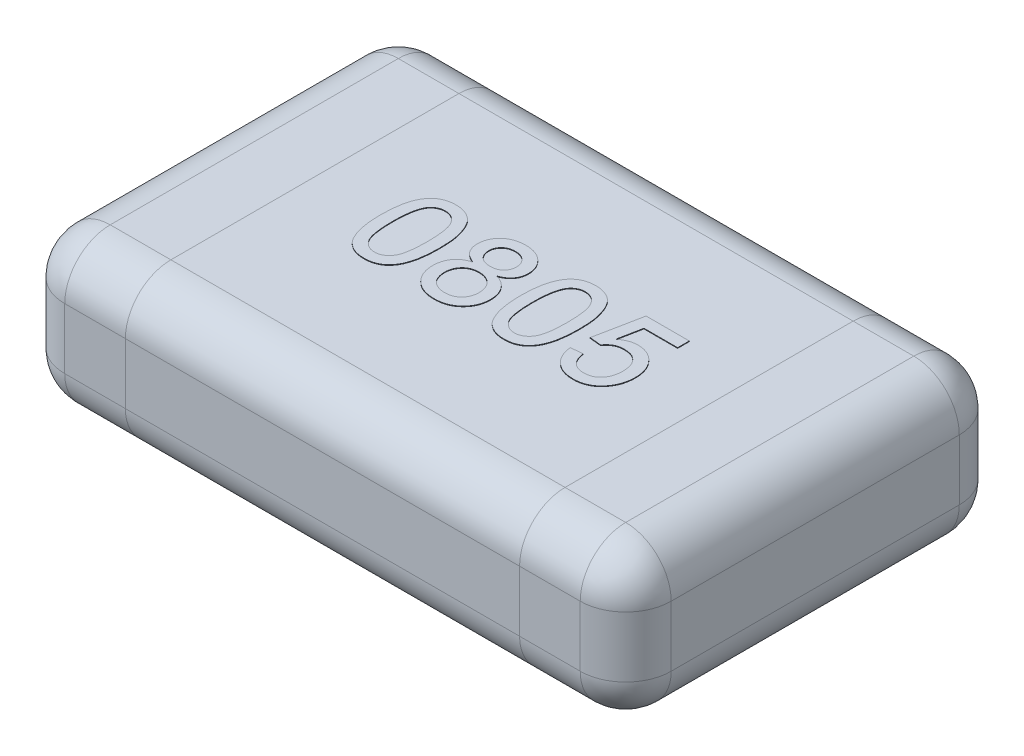
from build123d import *

# Parameters (mm, degrees)
SKETCH1_W      = 2
SKETCH1_H      = 1.25
EXTRUDE1_DEPTH = 0.5
FILLET1_R      = 0.15
EXTRUDE2_DEPTH = 0.002


with BuildPart() as part:
    # Sketch1 → Extrude1 (new body)
    with BuildSketch(Plane(origin=(0, 0, 0), x_dir=(1, 0, 0), z_dir=(0, 1, 0))):
        Rectangle(SKETCH1_W, SKETCH1_H)
    extrude(amount=EXTRUDE1_DEPTH)

    # Fillet1
    fillet1_edges = [part.edges().sort_by_distance(p)[0] for p in [
        (1, 0.5, 0),
        (0, 0.5, -0.625),
        (-1, 0.5, 0),
        (0, 0, -0.625),
        (1, 0, 0),
        (0, 0, 0.625),
        (-1, 0, 0),
        (0, 0.5, 0.625),
        (-1, 0.25, -0.625),
        (1, 0.25, -0.625),
        (1, 0.25, 0.625),
        (-1, 0.25, 0.625),
    ]]
    fillet(fillet1_edges, radius=FILLET1_R)

    # Sketch3 → Extrude2 (add)
    with BuildSketch(Plane(origin=(0, 0.5, 0), x_dir=(1, 0, 0), z_dir=(0, 1, 0))):
        with BuildLine():
            add(Edge.make_bspline(
                [(-0.430769231, -0.002043269), (-0.430730481, 0.002244006), (-0.430654586, 0.010640973), (-0.430183834, 0.022927244), (-0.42936194, 0.034595007), (-0.428135078, 0.045634129), (-0.426682243, 0.056069528), (-0.424793549, 0.06588631), (-0.422668494, 0.075106502), (-0.420118809, 0.083720493), (-0.41731754, 0.091802347), (-0.414139411, 0.0993391), (-0.410563584, 0.106322761), (-0.40676579, 0.112825754), (-0.402546105, 0.118746931), (-0.39815922, 0.124252464), (-0.393286323, 0.129140445), (-0.388130039, 0.13353664), (-0.382614442, 0.137416027), (-0.376768712, 0.140763469), (-0.370615345, 0.143719019), (-0.364037062, 0.145943957), (-0.357170429, 0.147757753), (-0.349962588, 0.149092003), (-0.342405598, 0.149878588), (-0.337241458, 0.149959072), (-0.334615385, 0.15)],
                knots=[0, 0, 0, 0, 1.2862e-05, 2.5191e-05, 3.688e-05, 4.7943e-05, 5.8507e-05, 6.8478e-05, 7.7924e-05, 8.6881e-05, 9.5415e-05, 0.000103574, 0.000111395, 0.00011894, 0.000126142, 0.000133191, 0.000140033, 0.000146812, 0.000153498, 0.000160229, 0.000167003, 0.000173941, 0.000181025, 0.000188297, 0.00019591, 0.000203786, 0.000203786, 0.000203786, 0.000203786], degree=3))
            add(Edge.make_bspline(
                [(-0.334615385, 0.15), (-0.330762593, 0.149886731), (-0.32319363, 0.149664209), (-0.312142905, 0.147849358), (-0.301728309, 0.144744777), (-0.291956608, 0.140556563), (-0.282994848, 0.135236725), (-0.274991618, 0.128769652), (-0.268033247, 0.121223246), (-0.262195674, 0.112508085), (-0.257093053, 0.102864591), (-0.252559996, 0.092249481), (-0.248462244, 0.080674651), (-0.24555439, 0.070313561), (-0.243480221, 0.061369501), (-0.242107285, 0.053992694), (-0.240967473, 0.046033077), (-0.240094223, 0.037509907), (-0.239377743, 0.028432744), (-0.238824437, 0.018795935), (-0.238543578, 0.008575397), (-0.238489398, 0.001562641), (-0.238461538, -0.002043269)],
                knots=[0, 0, 0, 0, 1.1554e-05, 2.2698e-05, 3.348e-05, 4.4085e-05, 5.4516e-05, 6.4643e-05, 7.485e-05, 8.5185e-05, 9.602e-05, 0.000107541, 0.000119781, 0.000132832, 0.000139801, 0.000147321, 0.000155335, 0.000163916, 0.000173019, 0.00018265, 0.000192871, 0.000203689, 0.000203689, 0.000203689, 0.000203689], degree=3))
            add(Edge.make_bspline(
                [(-0.238461538, -0.002043269), (-0.238501014, -0.006310407), (-0.238578138, -0.0146471), (-0.239036276, -0.026834856), (-0.239907695, -0.038414591), (-0.240979992, -0.049412832), (-0.242602154, -0.059800218), (-0.24435012, -0.069620882), (-0.246511923, -0.07883023), (-0.249034239, -0.087432298), (-0.251874941, -0.095472571), (-0.254990209, -0.103011813), (-0.258440668, -0.110044871), (-0.262329015, -0.11650315), (-0.266477343, -0.122472371), (-0.270916032, -0.127974928), (-0.275739189, -0.132931621), (-0.280941938, -0.137314631), (-0.28641881, -0.141262812), (-0.292278751, -0.144643304), (-0.298496114, -0.147443983), (-0.305029358, -0.149838424), (-0.311944772, -0.15159293), (-0.319187822, -0.152935977), (-0.326785196, -0.153726861), (-0.331969311, -0.153805841), (-0.334615385, -0.153846154)],
                knots=[0, 0, 0, 0, 1.2802e-05, 2.5011e-05, 3.658e-05, 4.7637e-05, 5.815e-05, 6.811e-05, 7.7556e-05, 8.6513e-05, 9.499e-05, 0.000103126, 0.000110974, 0.000118467, 0.000125719, 0.000132767, 0.000139652, 0.000146431, 0.000153152, 0.000159883, 0.000166686, 0.000173587, 0.000180729, 0.000188061, 0.000195673, 0.00020361, 0.00020361, 0.00020361, 0.00020361], degree=3))
            add(Edge.make_bspline(
                [(-0.334615385, -0.153846154), (-0.338084694, -0.153747192), (-0.344848894, -0.153554242), (-0.354727508, -0.152243272), (-0.363999114, -0.149935902), (-0.372741914, -0.146841394), (-0.380857634, -0.142702311), (-0.388385026, -0.137666308), (-0.395475345, -0.131850554), (-0.399556964, -0.127262057), (-0.401622596, -0.124939904)],
                knots=[0, 0, 0, 0, 1.0408e-05, 2.0292e-05, 2.9825e-05, 3.9025e-05, 4.8056e-05, 5.7073e-05, 6.616e-05, 7.5471e-05, 7.5471e-05, 7.5471e-05, 7.5471e-05], degree=3))
            add(Edge.make_bspline(
                [(-0.401622596, -0.124939904), (-0.404000186, -0.121510195), (-0.408902879, -0.11443799), (-0.414641055, -0.102379223), (-0.41975961, -0.089104214), (-0.423776737, -0.074352508), (-0.426923149, -0.058241513), (-0.429195644, -0.040739616), (-0.430481652, -0.021854376), (-0.430671207, -0.008796046), (-0.430769231, -0.002043269)],
                knots=[0, 0, 0, 0, 1.2501e-05, 2.5778e-05, 3.993e-05, 5.5152e-05, 7.157e-05, 8.9147e-05, 0.000108063, 0.000128321, 0.000128321, 0.000128321, 0.000128321], degree=3))
        make_face()
        with BuildLine():
            add(Edge.make_bspline(
                [(-0.392307692, -0.001923077), (-0.392269503, -0.007693168), (-0.3921964, -0.018738399), (-0.391432655, -0.034518417), (-0.390117899, -0.048754147), (-0.388379705, -0.061425879), (-0.386084585, -0.072550754), (-0.383202791, -0.082100422), (-0.379954324, -0.090189501), (-0.375934407, -0.096717734), (-0.371533042, -0.102039196), (-0.366988934, -0.106615825), (-0.362195175, -0.110505855), (-0.357183043, -0.113749347), (-0.351874773, -0.116205105), (-0.346328409, -0.117985045), (-0.340542745, -0.119009373), (-0.336602445, -0.119156549), (-0.334615385, -0.119230769)],
                knots=[0, 0, 0, 0, 1.7309e-05, 3.3134e-05, 4.7378e-05, 6.0186e-05, 7.1489e-05, 8.1413e-05, 9.0085e-05, 9.7558e-05, 0.000104306, 0.000110765, 0.000116876, 0.000122794, 0.000128628, 0.000134368, 0.000140227, 0.000146187, 0.000146187, 0.000146187, 0.000146187], degree=3))
            add(Edge.make_bspline(
                [(-0.334615385, -0.119230769), (-0.332628822, -0.119154928), (-0.328689509, -0.119004535), (-0.322890476, -0.118002795), (-0.317365692, -0.116131225), (-0.312065336, -0.11368414), (-0.307016775, -0.110514577), (-0.30224656, -0.106609854), (-0.297678514, -0.102035942), (-0.29329692, -0.096652628), (-0.289307629, -0.090094213), (-0.285998225, -0.082011723), (-0.283161342, -0.072445331), (-0.280853628, -0.061326124), (-0.279108264, -0.048674427), (-0.277801457, -0.03447818), (-0.2770326, -0.018718466), (-0.276960704, -0.007693194), (-0.276923077, -0.001923077)],
                knots=[0, 0, 0, 0, 5.96e-06, 1.1819e-05, 1.7578e-05, 2.3412e-05, 2.9298e-05, 3.5408e-05, 4.1867e-05, 4.8662e-05, 5.6186e-05, 6.4803e-05, 7.4784e-05, 8.6088e-05, 9.8836e-05, 0.00011308, 0.000128845, 0.000146154, 0.000146154, 0.000146154, 0.000146154], degree=3))
            add(Edge.make_bspline(
                [(-0.276923077, -0.001923077), (-0.276959499, 0.003726983), (-0.277029283, 0.014552283), (-0.27781797, 0.030028299), (-0.279053912, 0.044025088), (-0.280744486, 0.056555555), (-0.282991257, 0.067606095), (-0.285716284, 0.077200235), (-0.288963562, 0.085317512), (-0.292824563, 0.092039466), (-0.29712263, 0.097553292), (-0.301612368, 0.102325988), (-0.306406022, 0.10638501), (-0.31158852, 0.109641218), (-0.316992821, 0.112268205), (-0.322743102, 0.114076165), (-0.328782842, 0.115186918), (-0.332927837, 0.115317963), (-0.335036058, 0.115384615)],
                knots=[0, 0, 0, 0, 1.6949e-05, 3.2473e-05, 4.6473e-05, 5.9094e-05, 7.0385e-05, 8.0274e-05, 8.8979e-05, 9.6545e-05, 0.000103444, 0.000109906, 0.000116177, 0.000122229, 0.000128223, 0.000134153, 0.000140259, 0.000146579, 0.000146579, 0.000146579, 0.000146579], degree=3))
            add(Edge.make_bspline(
                [(-0.335036058, 0.115384615), (-0.337022993, 0.115332466), (-0.340940974, 0.115229635), (-0.346677413, 0.114248109), (-0.352113768, 0.112606778), (-0.357312323, 0.110383437), (-0.362143298, 0.107391258), (-0.366798279, 0.103897677), (-0.371059245, 0.099641138), (-0.373626865, 0.096459016), (-0.374939904, 0.094831731)],
                knots=[0, 0, 0, 0, 5.957e-06, 1.1747e-05, 1.7393e-05, 2.2965e-05, 2.8654e-05, 3.4399e-05, 4.0391e-05, 4.6662e-05, 4.6662e-05, 4.6662e-05, 4.6662e-05], degree=3))
            add(Edge.make_bspline(
                [(-0.374939904, 0.094831731), (-0.376369403, 0.092441753), (-0.379388204, 0.087394622), (-0.382766067, 0.078622501), (-0.385749937, 0.068597636), (-0.388206652, 0.057165788), (-0.389983913, 0.044346567), (-0.391386991, 0.03015486), (-0.392115838, 0.014570853), (-0.392241977, 0.003726591), (-0.392307692, -0.001923077)],
                knots=[0, 0, 0, 0, 8.341e-06, 1.7615e-05, 2.8091e-05, 3.9714e-05, 5.2649e-05, 6.6899e-05, 8.2483e-05, 9.9433e-05, 9.9433e-05, 9.9433e-05, 9.9433e-05], degree=3))
        make_face(mode=Mode.SUBTRACT)
        with BuildLine():
            add(Edge.make_bspline(
                [(-0.143028846, 0.014543269), (-0.146678167, 0.015970904), (-0.153675125, 0.018708154), (-0.163112218, 0.024186161), (-0.171099208, 0.030487887), (-0.177538027, 0.037765293), (-0.182445577, 0.045867936), (-0.185979208, 0.054692508), (-0.188048917, 0.06428817), (-0.188321315, 0.070923324), (-0.188461538, 0.074338942)],
                knots=[0, 0, 0, 0, 1.1742e-05, 2.2513e-05, 3.2603e-05, 4.214e-05, 5.1498e-05, 6.0884e-05, 7.0537e-05, 8.0779e-05, 8.0779e-05, 8.0779e-05, 8.0779e-05], degree=3))
            add(Edge.make_bspline(
                [(-0.188461538, 0.074338942), (-0.188395542, 0.07696711), (-0.188265988, 0.082126286), (-0.187146613, 0.089696504), (-0.185353774, 0.096950666), (-0.182809315, 0.103868299), (-0.179621525, 0.11050634), (-0.175599072, 0.11674318), (-0.170975512, 0.122755082), (-0.165559231, 0.128299027), (-0.159590583, 0.133376745), (-0.153125606, 0.137895415), (-0.146114829, 0.141590589), (-0.138675143, 0.144680065), (-0.130769761, 0.147098798), (-0.122370837, 0.148746091), (-0.113507979, 0.149793891), (-0.107434938, 0.149930227), (-0.104326923, 0.15)],
                knots=[0, 0, 0, 0, 7.881e-06, 1.547e-05, 2.2904e-05, 3.0261e-05, 3.7545e-05, 4.4948e-05, 5.2485e-05, 6.0262e-05, 6.8149e-05, 7.5968e-05, 8.3872e-05, 9.1874e-05, 0.000100106, 0.000108627, 0.00011752, 0.000126842, 0.000126842, 0.000126842, 0.000126842], degree=3))
            add(Edge.make_bspline(
                [(-0.104326923, 0.15), (-0.101199104, 0.149929518), (-0.095106464, 0.149792228), (-0.086196519, 0.148758507), (-0.077744593, 0.147025925), (-0.06975566, 0.144567827), (-0.062217127, 0.141425001), (-0.05517853, 0.137562056), (-0.048567409, 0.133042703), (-0.042552743, 0.127813048), (-0.037080114, 0.122135343), (-0.032338597, 0.1160526), (-0.02827195, 0.109706754), (-0.024911477, 0.103059254), (-0.022425386, 0.096034402), (-0.020530427, 0.088764549), (-0.019431263, 0.081163316), (-0.019298434, 0.076005089), (-0.019230769, 0.073377404)],
                knots=[0, 0, 0, 0, 9.382e-06, 1.8275e-05, 2.6867e-05, 3.5231e-05, 4.3312e-05, 5.1326e-05, 5.9277e-05, 6.7288e-05, 7.5194e-05, 8.29e-05, 9.0385e-05, 9.7776e-05, 0.00010519, 0.000112697, 0.000120286, 0.000128167, 0.000128167, 0.000128167, 0.000128167], degree=3))
            add(Edge.make_bspline(
                [(-0.019230769, 0.073377404), (-0.019340689, 0.070079507), (-0.019556221, 0.063612951), (-0.021752586, 0.054291357), (-0.025175809, 0.045589182), (-0.030123399, 0.037672273), (-0.036389338, 0.030458869), (-0.044164868, 0.024188177), (-0.053331905, 0.018718731), (-0.060152201, 0.015972556), (-0.063701923, 0.014543269)],
                knots=[0, 0, 0, 0, 9.878e-06, 1.9369e-05, 2.8564e-05, 3.782e-05, 4.7233e-05, 5.7098e-05, 6.7662e-05, 7.9128e-05, 7.9128e-05, 7.9128e-05, 7.9128e-05], degree=3))
            add(Edge.make_bspline(
                [(-0.063701923, 0.014543269), (-0.061462279, 0.013783016), (-0.057073548, 0.01229325), (-0.050869192, 0.009396685), (-0.045027977, 0.006273501), (-0.039516964, 0.002892652), (-0.034539578, -0.000997287), (-0.02992976, -0.00516632), (-0.02570689, -0.009673198), (-0.021928648, -0.014556251), (-0.018555448, -0.019712993), (-0.015667721, -0.025155995), (-0.01321523, -0.030807785), (-0.011119246, -0.036694571), (-0.009588296, -0.042857817), (-0.008517111, -0.049269202), (-0.007837474, -0.055894934), (-0.0077412, -0.060394987), (-0.007692308, -0.062680288)],
                knots=[0, 0, 0, 0, 7.091e-06, 1.3894e-05, 2.0509e-05, 2.6962e-05, 3.326e-05, 3.9429e-05, 4.5594e-05, 5.1761e-05, 5.7929e-05, 6.4058e-05, 7.0221e-05, 7.6399e-05, 8.2783e-05, 8.9244e-05, 9.5888e-05, 0.000102743, 0.000102743, 0.000102743, 0.000102743], degree=3))
            add(Edge.make_bspline(
                [(-0.007692308, -0.062680288), (-0.007768742, -0.065830053), (-0.007919323, -0.07203533), (-0.009242375, -0.081143948), (-0.011244211, -0.089894018), (-0.014163119, -0.098248578), (-0.017891291, -0.106213532), (-0.022503083, -0.113777315), (-0.027953185, -0.120932146), (-0.034080828, -0.127700265), (-0.040931529, -0.133818351), (-0.048342718, -0.139209736), (-0.056342204, -0.143725707), (-0.064832924, -0.147464915), (-0.073855537, -0.150362788), (-0.083398443, -0.152391913), (-0.093458467, -0.153600168), (-0.100337199, -0.15376306), (-0.103846154, -0.153846154)],
                knots=[0, 0, 0, 0, 9.444e-06, 1.8606e-05, 2.7557e-05, 3.6337e-05, 4.5101e-05, 5.3893e-05, 6.2859e-05, 7.2048e-05, 8.1241e-05, 9.0365e-05, 9.9489e-05, 0.000108745, 0.000118153, 0.000127865, 0.000137973, 0.000148498, 0.000148498, 0.000148498, 0.000148498], degree=3))
            add(Edge.make_bspline(
                [(-0.103846154, -0.153846154), (-0.107354757, -0.153761269), (-0.114232802, -0.153594866), (-0.124302017, -0.152411313), (-0.13383127, -0.150290202), (-0.142842151, -0.147389384), (-0.15138354, -0.143751415), (-0.159329302, -0.139133687), (-0.166788901, -0.133749133), (-0.173644365, -0.127593205), (-0.179822907, -0.120825808), (-0.185201165, -0.113565311), (-0.18978558, -0.105923451), (-0.193558454, -0.097857148), (-0.196434244, -0.089366329), (-0.198452508, -0.080482873), (-0.199777955, -0.071213566), (-0.199924942, -0.064888503), (-0.2, -0.061658654)],
                knots=[0, 0, 0, 0, 1.0525e-05, 2.0633e-05, 3.0358e-05, 3.9766e-05, 4.8998e-05, 5.8152e-05, 6.7276e-05, 7.6554e-05, 8.5742e-05, 9.4721e-05, 0.000103615, 0.000112434, 0.000121385, 0.000130452, 0.000139733, 0.000149418, 0.000149418, 0.000149418, 0.000149418], degree=3))
            add(Edge.make_bspline(
                [(-0.2, -0.061658654), (-0.199947829, -0.05925379), (-0.199845461, -0.054535032), (-0.199220126, -0.047613898), (-0.197973847, -0.04101733), (-0.19636856, -0.034706454), (-0.194330348, -0.028665483), (-0.191815826, -0.022941855), (-0.188765062, -0.017549405), (-0.185299194, -0.012453043), (-0.181374488, -0.007688549), (-0.177054552, -0.003297645), (-0.172323696, 0.000669723), (-0.16728823, 0.004329433), (-0.161737085, 0.007422605), (-0.155876706, 0.010261167), (-0.149606339, 0.012681934), (-0.145243302, 0.01391661), (-0.143028846, 0.014543269)],
                knots=[0, 0, 0, 0, 7.216e-06, 1.4158e-05, 2.0818e-05, 2.7333e-05, 3.3681e-05, 3.9923e-05, 4.6058e-05, 5.2242e-05, 5.839e-05, 6.4552e-05, 7.0692e-05, 7.6896e-05, 8.3194e-05, 8.9726e-05, 9.6422e-05, 0.000103324, 0.000103324, 0.000103324, 0.000103324], degree=3))
        make_face()
        with BuildLine():
            add(Edge.make_bspline(
                [(-0.15, 0.074158654), (-0.149885847, 0.071096846), (-0.149665252, 0.065180074), (-0.147266257, 0.056775734), (-0.143514926, 0.049226279), (-0.139117148, 0.043751589), (-0.134900784, 0.0400214), (-0.131381647, 0.037530885), (-0.127535911, 0.035416488), (-0.123335716, 0.033773046), (-0.11888279, 0.032317058), (-0.114023557, 0.031503267), (-0.108872232, 0.030841703), (-0.105311001, 0.03079379), (-0.103485577, 0.030769231)],
                knots=[0, 0, 0, 0, 9.163e-06, 1.7707e-05, 2.5985e-05, 3.4319e-05, 3.8576e-05, 4.2845e-05, 4.7228e-05, 5.1704e-05, 5.6361e-05, 6.1252e-05, 6.6455e-05, 7.1927e-05, 7.1927e-05, 7.1927e-05, 7.1927e-05], degree=3))
            add(Edge.make_bspline(
                [(-0.103485577, 0.030769231), (-0.101700447, 0.030794697), (-0.098219542, 0.030844356), (-0.093184237, 0.031492433), (-0.088425891, 0.032358), (-0.08401482, 0.033669634), (-0.079900096, 0.035375141), (-0.076148645, 0.037477611), (-0.072648204, 0.039893951), (-0.068555701, 0.043652639), (-0.064163992, 0.048935583), (-0.060400089, 0.056147793), (-0.058054585, 0.064038379), (-0.057815187, 0.069534632), (-0.057692308, 0.072355769)],
                knots=[0, 0, 0, 0, 5.352e-06, 1.0435e-05, 1.5209e-05, 1.9848e-05, 2.4212e-05, 2.8543e-05, 3.2728e-05, 3.694e-05, 4.5181e-05, 5.3192e-05, 6.1199e-05, 6.9644e-05, 6.9644e-05, 6.9644e-05, 6.9644e-05], degree=3))
            add(Edge.make_bspline(
                [(-0.057692308, 0.072355769), (-0.05784036, 0.075275526), (-0.05813006, 0.080988733), (-0.060469834, 0.089190299), (-0.06440905, 0.096618469), (-0.068909058, 0.102043156), (-0.073073957, 0.105973023), (-0.076637241, 0.108474646), (-0.080467784, 0.110603749), (-0.084580166, 0.112342448), (-0.088980333, 0.113744726), (-0.093680205, 0.114664689), (-0.098660033, 0.115309891), (-0.102081073, 0.115359183), (-0.103846154, 0.115384615)],
                knots=[0, 0, 0, 0, 8.749e-06, 1.7119e-05, 2.5345e-05, 3.3802e-05, 3.814e-05, 4.2492e-05, 4.6823e-05, 5.1266e-05, 5.5866e-05, 6.0651e-05, 6.5615e-05, 7.0907e-05, 7.0907e-05, 7.0907e-05, 7.0907e-05], degree=3))
            add(Edge.make_bspline(
                [(-0.103846154, 0.115384615), (-0.105611431, 0.115360006), (-0.109052754, 0.11531203), (-0.114065054, 0.114647467), (-0.118809467, 0.113812789), (-0.123242222, 0.112473285), (-0.127344894, 0.110722865), (-0.131160335, 0.108592567), (-0.134716868, 0.106154844), (-0.138911028, 0.102400216), (-0.14330372, 0.097117152), (-0.147173559, 0.09002013), (-0.149565244, 0.08228198), (-0.149853286, 0.076899968), (-0.15, 0.074158654)],
                knots=[0, 0, 0, 0, 5.292e-06, 1.0316e-05, 1.5148e-05, 1.973e-05, 2.4173e-05, 2.8504e-05, 3.2821e-05, 3.7078e-05, 4.5358e-05, 5.3291e-05, 6.12e-05, 6.941e-05, 6.941e-05, 6.941e-05, 6.941e-05], degree=3))
        make_face(mode=Mode.SUBTRACT)
        with BuildLine():
            add(Edge.make_bspline(
                [(-0.161538462, -0.0609375), (-0.161471953, -0.063405403), (-0.16133876, -0.06834771), (-0.160170375, -0.075688083), (-0.158187867, -0.082891764), (-0.155646938, -0.089965559), (-0.1520628, -0.096623957), (-0.147309829, -0.102567066), (-0.141345741, -0.107563675), (-0.134534427, -0.111784999), (-0.127101532, -0.115107544), (-0.119356237, -0.117426794), (-0.111498446, -0.118959238), (-0.106196901, -0.119140248), (-0.103545673, -0.119230769)],
                knots=[0, 0, 0, 0, 7.401e-06, 1.4821e-05, 2.2226e-05, 2.9795e-05, 3.7325e-05, 4.4805e-05, 5.2477e-05, 6.0548e-05, 6.8779e-05, 7.6821e-05, 8.4765e-05, 9.2713e-05, 9.2713e-05, 9.2713e-05, 9.2713e-05], degree=3))
            add(Edge.make_bspline(
                [(-0.103545673, -0.119230769), (-0.10135945, -0.119193736), (-0.097112242, -0.119121792), (-0.090921142, -0.11829967), (-0.085087726, -0.117052243), (-0.079585269, -0.115341816), (-0.074494761, -0.113001839), (-0.069733304, -0.110266914), (-0.065349603, -0.106961547), (-0.061344897, -0.10318929), (-0.057759976, -0.099016466), (-0.054689038, -0.094514901), (-0.052010223, -0.08981119), (-0.049823092, -0.08480382), (-0.048241444, -0.079482465), (-0.04702098, -0.073943134), (-0.046284709, -0.068128692), (-0.046198099, -0.064164781), (-0.046153846, -0.062139423)],
                knots=[0, 0, 0, 0, 6.555e-06, 1.2734e-05, 1.8699e-05, 2.4438e-05, 2.9979e-05, 3.5473e-05, 4.0881e-05, 4.6408e-05, 5.1949e-05, 5.735e-05, 6.2732e-05, 6.8169e-05, 7.37e-05, 7.9358e-05, 8.5173e-05, 9.1247e-05, 9.1247e-05, 9.1247e-05, 9.1247e-05], degree=3))
            add(Edge.make_bspline(
                [(-0.046153846, -0.062139423), (-0.046199509, -0.06007431), (-0.046288909, -0.056031148), (-0.047006468, -0.050089091), (-0.048295369, -0.044452304), (-0.0499529, -0.039035631), (-0.052199329, -0.033933308), (-0.054895853, -0.029072172), (-0.058197999, -0.024580352), (-0.061819065, -0.020305352), (-0.0659169, -0.016435488), (-0.070442192, -0.013098358), (-0.075251524, -0.010151107), (-0.080490384, -0.007890317), (-0.086043352, -0.006079372), (-0.09193681, -0.004763512), (-0.098194786, -0.003959162), (-0.102481472, -0.003884551), (-0.1046875, -0.003846154)],
                knots=[0, 0, 0, 0, 6.195e-06, 1.2128e-05, 1.7916e-05, 2.3523e-05, 2.9094e-05, 3.4611e-05, 4.0164e-05, 4.579e-05, 5.1402e-05, 5.7027e-05, 6.2633e-05, 6.8284e-05, 7.4099e-05, 8.0135e-05, 8.6374e-05, 9.2989e-05, 9.2989e-05, 9.2989e-05, 9.2989e-05], degree=3))
            add(Edge.make_bspline(
                [(-0.1046875, -0.003846154), (-0.106833622, -0.003884933), (-0.11104069, -0.003960952), (-0.117152397, -0.004769858), (-0.122938306, -0.00601207), (-0.128347512, -0.007830212), (-0.133447646, -0.010102166), (-0.13814543, -0.012958985), (-0.142524672, -0.016274938), (-0.1464516, -0.020129101), (-0.149994708, -0.02431577), (-0.153058103, -0.028803867), (-0.155764303, -0.033489281), (-0.157817981, -0.038525757), (-0.159556235, -0.043750476), (-0.160642919, -0.049264843), (-0.161415415, -0.055006205), (-0.161496847, -0.058931505), (-0.161538462, -0.0609375)],
                knots=[0, 0, 0, 0, 6.435e-06, 1.2614e-05, 1.8461e-05, 2.4162e-05, 2.9703e-05, 3.5176e-05, 4.0621e-05, 4.6146e-05, 5.1647e-05, 5.7048e-05, 6.243e-05, 6.7843e-05, 7.3336e-05, 7.8923e-05, 8.4677e-05, 9.0691e-05, 9.0691e-05, 9.0691e-05, 9.0691e-05], degree=3))
        make_face(mode=Mode.SUBTRACT)
        with BuildLine():
            add(Edge.make_bspline(
                [(0.030769231, -0.002043269), (0.030807981, 0.002244006), (0.030883876, 0.010640973), (0.031354627, 0.022927244), (0.032176522, 0.034595007), (0.033403384, 0.045634129), (0.034856218, 0.056069528), (0.036744912, 0.06588631), (0.038869967, 0.075106502), (0.041419652, 0.083720493), (0.044220921, 0.091802347), (0.047399051, 0.0993391), (0.050974877, 0.106322761), (0.054772671, 0.112825754), (0.058992356, 0.118746931), (0.063379241, 0.124252464), (0.068252138, 0.129140445), (0.073408422, 0.13353664), (0.07892402, 0.137416027), (0.084769749, 0.140763469), (0.090923117, 0.143719019), (0.097501399, 0.145943957), (0.104368033, 0.147757753), (0.111575873, 0.149092003), (0.119132863, 0.149878588), (0.124297003, 0.149959072), (0.126923077, 0.15)],
                knots=[0, 0, 0, 0, 1.2862e-05, 2.5191e-05, 3.688e-05, 4.7943e-05, 5.8507e-05, 6.8478e-05, 7.7924e-05, 8.6881e-05, 9.5415e-05, 0.000103574, 0.000111395, 0.00011894, 0.000126142, 0.000133191, 0.000140033, 0.000146812, 0.000153498, 0.000160229, 0.000167003, 0.000173941, 0.000181025, 0.000188297, 0.00019591, 0.000203786, 0.000203786, 0.000203786, 0.000203786], degree=3))
            add(Edge.make_bspline(
                [(0.126923077, 0.15), (0.130775868, 0.149886731), (0.138344831, 0.149664209), (0.149395556, 0.147849358), (0.159810153, 0.144744777), (0.169581854, 0.140556563), (0.178543614, 0.135236725), (0.186546843, 0.128769652), (0.193505214, 0.121223246), (0.199342787, 0.112508085), (0.204445409, 0.102864591), (0.208978466, 0.092249481), (0.213076217, 0.080674651), (0.215984071, 0.070313561), (0.218058241, 0.061369501), (0.219431176, 0.053992694), (0.220570988, 0.046033077), (0.221444238, 0.037509907), (0.222160719, 0.028432744), (0.222714024, 0.018795935), (0.222994883, 0.008575397), (0.223049064, 0.001562641), (0.223076923, -0.002043269)],
                knots=[0, 0, 0, 0, 1.1554e-05, 2.2698e-05, 3.348e-05, 4.4085e-05, 5.4516e-05, 6.4643e-05, 7.485e-05, 8.5185e-05, 9.602e-05, 0.000107541, 0.000119781, 0.000132832, 0.000139801, 0.000147321, 0.000155335, 0.000163916, 0.000173019, 0.00018265, 0.000192871, 0.000203689, 0.000203689, 0.000203689, 0.000203689], degree=3))
            add(Edge.make_bspline(
                [(0.223076923, -0.002043269), (0.223037447, -0.006310407), (0.222960323, -0.0146471), (0.222502186, -0.026834856), (0.221630766, -0.038414591), (0.220558469, -0.049412832), (0.218936308, -0.059800218), (0.217188341, -0.069620882), (0.215026538, -0.07883023), (0.212504222, -0.087432298), (0.209663521, -0.095472571), (0.206548253, -0.103011813), (0.203097794, -0.110044871), (0.199209446, -0.11650315), (0.195061119, -0.122472371), (0.190622429, -0.127974928), (0.185799273, -0.132931621), (0.180596523, -0.137314631), (0.175119652, -0.141262812), (0.16925971, -0.144643304), (0.163042348, -0.147443983), (0.156509104, -0.149838424), (0.149593689, -0.15159293), (0.142350639, -0.152935977), (0.134753266, -0.153726861), (0.129569151, -0.153805841), (0.126923077, -0.153846154)],
                knots=[0, 0, 0, 0, 1.2802e-05, 2.5011e-05, 3.658e-05, 4.7637e-05, 5.815e-05, 6.811e-05, 7.7556e-05, 8.6513e-05, 9.499e-05, 0.000103126, 0.000110974, 0.000118467, 0.000125719, 0.000132767, 0.000139652, 0.000146431, 0.000153152, 0.000159883, 0.000166686, 0.000173587, 0.000180729, 0.000188061, 0.000195673, 0.00020361, 0.00020361, 0.00020361, 0.00020361], degree=3))
            add(Edge.make_bspline(
                [(0.126923077, -0.153846154), (0.123453767, -0.153747192), (0.116689568, -0.153554242), (0.106810954, -0.152243272), (0.097539347, -0.149935902), (0.088796548, -0.146841394), (0.080680827, -0.142702311), (0.073153436, -0.137666308), (0.066063116, -0.131850554), (0.061981497, -0.127262057), (0.059915865, -0.124939904)],
                knots=[0, 0, 0, 0, 1.0408e-05, 2.0292e-05, 2.9825e-05, 3.9025e-05, 4.8056e-05, 5.7073e-05, 6.616e-05, 7.5471e-05, 7.5471e-05, 7.5471e-05, 7.5471e-05], degree=3))
            add(Edge.make_bspline(
                [(0.059915865, -0.124939904), (0.057538275, -0.121510195), (0.052635583, -0.11443799), (0.046897407, -0.102379223), (0.041778852, -0.089104214), (0.037761725, -0.074352508), (0.034615313, -0.058241513), (0.032342818, -0.040739616), (0.031056809, -0.021854376), (0.030867254, -0.008796046), (0.030769231, -0.002043269)],
                knots=[0, 0, 0, 0, 1.2501e-05, 2.5778e-05, 3.993e-05, 5.5152e-05, 7.157e-05, 8.9147e-05, 0.000108063, 0.000128321, 0.000128321, 0.000128321, 0.000128321], degree=3))
        make_face()
        with BuildLine():
            add(Edge.make_bspline(
                [(0.069230769, -0.001923077), (0.069268958, -0.007693168), (0.069342061, -0.018738399), (0.070105807, -0.034518417), (0.071420563, -0.048754147), (0.073158757, -0.061425879), (0.075453876, -0.072550754), (0.07833567, -0.082100422), (0.081584138, -0.090189501), (0.085604055, -0.096717734), (0.090005419, -0.102039196), (0.094549528, -0.106615825), (0.099343287, -0.110505855), (0.104355418, -0.113749347), (0.109663688, -0.116205105), (0.115210052, -0.117985045), (0.120995717, -0.119009373), (0.124936017, -0.119156549), (0.126923077, -0.119230769)],
                knots=[0, 0, 0, 0, 1.7309e-05, 3.3134e-05, 4.7378e-05, 6.0186e-05, 7.1489e-05, 8.1413e-05, 9.0085e-05, 9.7558e-05, 0.000104306, 0.000110765, 0.000116876, 0.000122794, 0.000128628, 0.000134368, 0.000140227, 0.000146187, 0.000146187, 0.000146187, 0.000146187], degree=3))
            add(Edge.make_bspline(
                [(0.126923077, -0.119230769), (0.128909639, -0.119154928), (0.132848953, -0.119004535), (0.138647986, -0.118002795), (0.14417277, -0.116131225), (0.149473125, -0.11368414), (0.154521686, -0.110514577), (0.159291902, -0.106609854), (0.163859948, -0.102035942), (0.168241542, -0.096652628), (0.172230832, -0.090094213), (0.175540237, -0.082011723), (0.17837712, -0.072445331), (0.180684833, -0.061326124), (0.182430197, -0.048674427), (0.183737005, -0.03447818), (0.184505861, -0.018718466), (0.184577757, -0.007693194), (0.184615385, -0.001923077)],
                knots=[0, 0, 0, 0, 5.96e-06, 1.1819e-05, 1.7578e-05, 2.3412e-05, 2.9298e-05, 3.5408e-05, 4.1867e-05, 4.8662e-05, 5.6186e-05, 6.4803e-05, 7.4784e-05, 8.6088e-05, 9.8836e-05, 0.00011308, 0.000128845, 0.000146154, 0.000146154, 0.000146154, 0.000146154], degree=3))
            add(Edge.make_bspline(
                [(0.184615385, -0.001923077), (0.184578962, 0.003726983), (0.184509178, 0.014552283), (0.183720492, 0.030028299), (0.182484549, 0.044025088), (0.180793976, 0.056555555), (0.178547205, 0.067606095), (0.175822177, 0.077200235), (0.1725749, 0.085317512), (0.168713899, 0.092039466), (0.164415832, 0.097553292), (0.159926094, 0.102325988), (0.15513244, 0.10638501), (0.149949942, 0.109641218), (0.144545641, 0.112268205), (0.13879536, 0.114076165), (0.13275562, 0.115186918), (0.128610625, 0.115317963), (0.126502404, 0.115384615)],
                knots=[0, 0, 0, 0, 1.6949e-05, 3.2473e-05, 4.6473e-05, 5.9094e-05, 7.0385e-05, 8.0274e-05, 8.8979e-05, 9.6545e-05, 0.000103444, 0.000109906, 0.000116177, 0.000122229, 0.000128223, 0.000134153, 0.000140259, 0.000146579, 0.000146579, 0.000146579, 0.000146579], degree=3))
            add(Edge.make_bspline(
                [(0.126502404, 0.115384615), (0.124515469, 0.115332466), (0.120597487, 0.115229635), (0.114861049, 0.114248109), (0.109424694, 0.112606778), (0.104226139, 0.110383437), (0.099395163, 0.107391258), (0.094740182, 0.103897677), (0.090479217, 0.099641138), (0.087911597, 0.096459016), (0.086598558, 0.094831731)],
                knots=[0, 0, 0, 0, 5.957e-06, 1.1747e-05, 1.7393e-05, 2.2965e-05, 2.8654e-05, 3.4399e-05, 4.0391e-05, 4.6662e-05, 4.6662e-05, 4.6662e-05, 4.6662e-05], degree=3))
            add(Edge.make_bspline(
                [(0.086598558, 0.094831731), (0.085169059, 0.092441753), (0.082150258, 0.087394622), (0.078772395, 0.078622501), (0.075788524, 0.068597636), (0.07333181, 0.057165788), (0.071554549, 0.044346567), (0.07015147, 0.03015486), (0.069422623, 0.014570853), (0.069296485, 0.003726591), (0.069230769, -0.001923077)],
                knots=[0, 0, 0, 0, 8.341e-06, 1.7615e-05, 2.8091e-05, 3.9714e-05, 5.2649e-05, 6.6899e-05, 8.2483e-05, 9.9433e-05, 9.9433e-05, 9.9433e-05, 9.9433e-05], degree=3))
        make_face(mode=Mode.SUBTRACT)
        with BuildLine():
            Line((0.261538462, -0.069230769), (0.3, -0.065384615))
            add(Edge.make_bspline(
                [(0.3, -0.065384615), (0.30038083, -0.067551712), (0.301121602, -0.071767052), (0.302533227, -0.077868882), (0.304366525, -0.083537652), (0.306426438, -0.088822457), (0.308874991, -0.093667418), (0.31152802, -0.098149034), (0.314656724, -0.102108221), (0.317946137, -0.105752048), (0.321556518, -0.108962904), (0.325522707, -0.111669767), (0.329734042, -0.114031341), (0.334241818, -0.115964892), (0.339052942, -0.11738015), (0.344106181, -0.118499376), (0.349466606, -0.119063349), (0.353123988, -0.119174249), (0.354987981, -0.119230769)],
                knots=[0, 0, 0, 0, 6.601e-06, 1.2839e-05, 1.8769e-05, 2.4461e-05, 2.9836e-05, 3.5041e-05, 4.0053e-05, 4.4945e-05, 4.9756e-05, 5.4507e-05, 5.9322e-05, 6.4223e-05, 6.9184e-05, 7.4347e-05, 7.9729e-05, 8.5323e-05, 8.5323e-05, 8.5323e-05, 8.5323e-05], degree=3))
            add(Edge.make_bspline(
                [(0.354987981, -0.119230769), (0.357274683, -0.119175516), (0.361746428, -0.119067466), (0.368251971, -0.118153619), (0.374396983, -0.116646792), (0.380152061, -0.1145381), (0.385584673, -0.111915691), (0.390514594, -0.10852015), (0.395210632, -0.104703226), (0.399370595, -0.10015272), (0.403157331, -0.095198734), (0.406425568, -0.089791248), (0.409176962, -0.08400616), (0.411493335, -0.077844578), (0.413203807, -0.071271305), (0.414461998, -0.064321309), (0.415269706, -0.056990161), (0.415345769, -0.051965295), (0.415384615, -0.049399038)],
                knots=[0, 0, 0, 0, 6.858e-06, 1.341e-05, 1.9663e-05, 2.5804e-05, 3.177e-05, 3.7704e-05, 4.3721e-05, 4.9886e-05, 5.6149e-05, 6.2405e-05, 6.8802e-05, 7.5343e-05, 8.2122e-05, 8.9147e-05, 9.652e-05, 0.000104216, 0.000104216, 0.000104216, 0.000104216], degree=3))
            add(Edge.make_bspline(
                [(0.415384615, -0.049399038), (0.415340463, -0.04695343), (0.415254489, -0.042191262), (0.414530446, -0.035256754), (0.4133089, -0.028736217), (0.411728333, -0.022557785), (0.409549721, -0.016818003), (0.406965765, -0.01143365), (0.403800311, -0.006518997), (0.400278533, -0.001921019), (0.396256219, 0.002200882), (0.391679027, 0.005681305), (0.386726518, 0.008727379), (0.381298942, 0.011197555), (0.375393105, 0.013032802), (0.369067694, 0.01444486), (0.362257073, 0.015187545), (0.357573654, 0.015317745), (0.355168269, 0.015384615)],
                knots=[0, 0, 0, 0, 7.336e-06, 1.4284e-05, 2.0885e-05, 2.7226e-05, 3.3387e-05, 3.9274e-05, 4.5109e-05, 5.0891e-05, 5.6628e-05, 6.2325e-05, 6.8097e-05, 7.4041e-05, 8.016e-05, 8.662e-05, 9.3456e-05, 0.000100674, 0.000100674, 0.000100674, 0.000100674], degree=3))
            add(Edge.make_bspline(
                [(0.355168269, 0.015384615), (0.35217729, 0.015297123), (0.346441268, 0.015129334), (0.338199195, 0.013717778), (0.330696137, 0.011437589), (0.324017044, 0.008039245), (0.318049605, 0.003979366), (0.312669849, -0.000614572), (0.307833414, -0.005739463), (0.305180433, -0.009597911), (0.303846154, -0.011538462)],
                knots=[0, 0, 0, 0, 8.967e-06, 1.7197e-05, 2.5009e-05, 3.24e-05, 3.9584e-05, 4.6617e-05, 5.3591e-05, 6.0647e-05, 6.0647e-05, 6.0647e-05, 6.0647e-05], degree=3))
            Line((0.303846154, -0.011538462), (0.265384615, -0.007692308))
            Line((0.265384615, -0.007692308), (0.296153846, 0.146153846))
            Line((0.296153846, 0.146153846), (0.438461538, 0.146153846))
            Line((0.438461538, 0.146153846), (0.438461538, 0.107692308))
            Line((0.438461538, 0.107692308), (0.327584135, 0.107692308))
            Line((0.327584135, 0.107692308), (0.312319712, 0.029987981))
            add(Edge.make_bspline(
                [(0.312319712, 0.029987981), (0.314441916, 0.031580513), (0.318609591, 0.034707994), (0.325110415, 0.038803019), (0.331704195, 0.042254851), (0.338352546, 0.045081612), (0.345108278, 0.047283653), (0.351930625, 0.04881353), (0.358842815, 0.049847511), (0.363477847, 0.049949025), (0.365805288, 0.05)],
                knots=[0, 0, 0, 0, 7.957e-06, 1.5627e-05, 2.3019e-05, 3.0263e-05, 3.7276e-05, 4.4303e-05, 5.1221e-05, 5.8199e-05, 5.8199e-05, 5.8199e-05, 5.8199e-05], degree=3))
            add(Edge.make_bspline(
                [(0.365805288, 0.05), (0.368834296, 0.049920638), (0.374799147, 0.049764354), (0.383588562, 0.048480285), (0.391992721, 0.046300494), (0.400077546, 0.043364633), (0.407736429, 0.039472647), (0.415046948, 0.034760279), (0.42197959, 0.029188686), (0.428495161, 0.022862992), (0.434405043, 0.015840807), (0.43969458, 0.008351149), (0.444014786, 0.000244097), (0.447648375, -0.008268674), (0.450388905, -0.017326903), (0.452469064, -0.026802035), (0.453581256, -0.036812532), (0.453756472, -0.043627351), (0.453846154, -0.047115385)],
                knots=[0, 0, 0, 0, 9.084e-06, 1.7889e-05, 2.6576e-05, 3.5094e-05, 4.3641e-05, 5.2292e-05, 6.1143e-05, 7.028e-05, 7.9491e-05, 8.8643e-05, 9.7732e-05, 0.000106996, 0.000116367, 0.00012608, 0.000136061, 0.000146526, 0.000146526, 0.000146526, 0.000146526], degree=3))
            add(Edge.make_bspline(
                [(0.453846154, -0.047115385), (0.453778054, -0.050443542), (0.453643537, -0.057017604), (0.452541146, -0.066705698), (0.450725217, -0.07604094), (0.44829419, -0.085050973), (0.445009547, -0.093684628), (0.441025582, -0.101969792), (0.436429854, -0.109992917), (0.432744319, -0.114938711), (0.430889423, -0.117427885)],
                knots=[0, 0, 0, 0, 9.982e-06, 1.9718e-05, 2.9206e-05, 3.8493e-05, 4.7679e-05, 5.6872e-05, 6.6056e-05, 7.5361e-05, 7.5361e-05, 7.5361e-05, 7.5361e-05], degree=3))
            add(Edge.make_bspline(
                [(0.430889423, -0.117427885), (0.428532829, -0.120333533), (0.423897156, -0.126049256), (0.415870539, -0.133467922), (0.407241812, -0.139772767), (0.397959625, -0.144894997), (0.388086291, -0.149011142), (0.377500519, -0.151750282), (0.36633022, -0.153589724), (0.358661594, -0.153759501), (0.354747596, -0.153846154)],
                knots=[0, 0, 0, 0, 1.1212e-05, 2.2054e-05, 3.2681e-05, 4.3199e-05, 5.379e-05, 6.4679e-05, 7.5933e-05, 8.7664e-05, 8.7664e-05, 8.7664e-05, 8.7664e-05], degree=3))
            add(Edge.make_bspline(
                [(0.354747596, -0.153846154), (0.351519169, -0.153780666), (0.345203717, -0.153652558), (0.335956773, -0.152538848), (0.327161835, -0.150762874), (0.318816148, -0.148215578), (0.31089457, -0.144996831), (0.303489178, -0.140907918), (0.29647146, -0.136230457), (0.289995781, -0.130820335), (0.284095595, -0.124785969), (0.278808909, -0.118255214), (0.274207265, -0.111223812), (0.270292885, -0.103733837), (0.26703043, -0.095792473), (0.264534523, -0.087345515), (0.262557557, -0.078475843), (0.261881722, -0.072344773), (0.261538462, -0.069230769)],
                knots=[0, 0, 0, 0, 9.682e-06, 1.894e-05, 2.7898e-05, 3.6567e-05, 4.5082e-05, 5.3499e-05, 6.19e-05, 7.0348e-05, 7.8763e-05, 8.7181e-05, 9.5515e-05, 0.000103929, 0.0001125, 0.000121226, 0.000130326, 0.000139718, 0.000139718, 0.000139718, 0.000139718], degree=3))
        make_face()
    extrude(amount=EXTRUDE2_DEPTH)


solid = part.part
